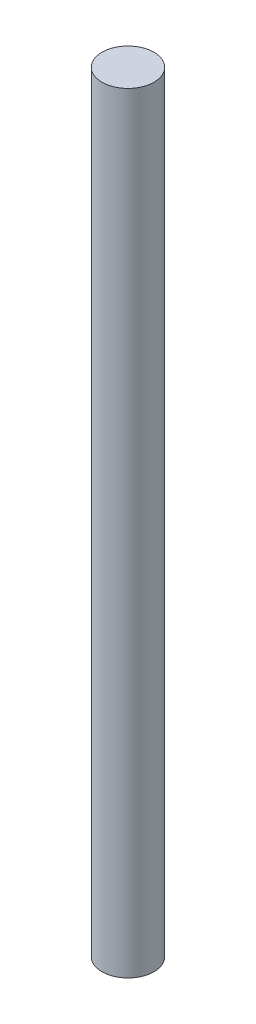
from build123d import *

# Parameters (mm, degrees)
SKETCH1_R           = 1.5
BOSS_EXTRUDE1_DEPTH = 44.45


with BuildPart() as part:
    # Sketch1 → Boss-Extrude1 (new body)
    with BuildSketch(Plane(origin=(0, 0, 0), x_dir=(1, 0, 0), z_dir=(0, 1, 0))):
        Circle(SKETCH1_R)
    extrude(amount=BOSS_EXTRUDE1_DEPTH)


solid = part.part
